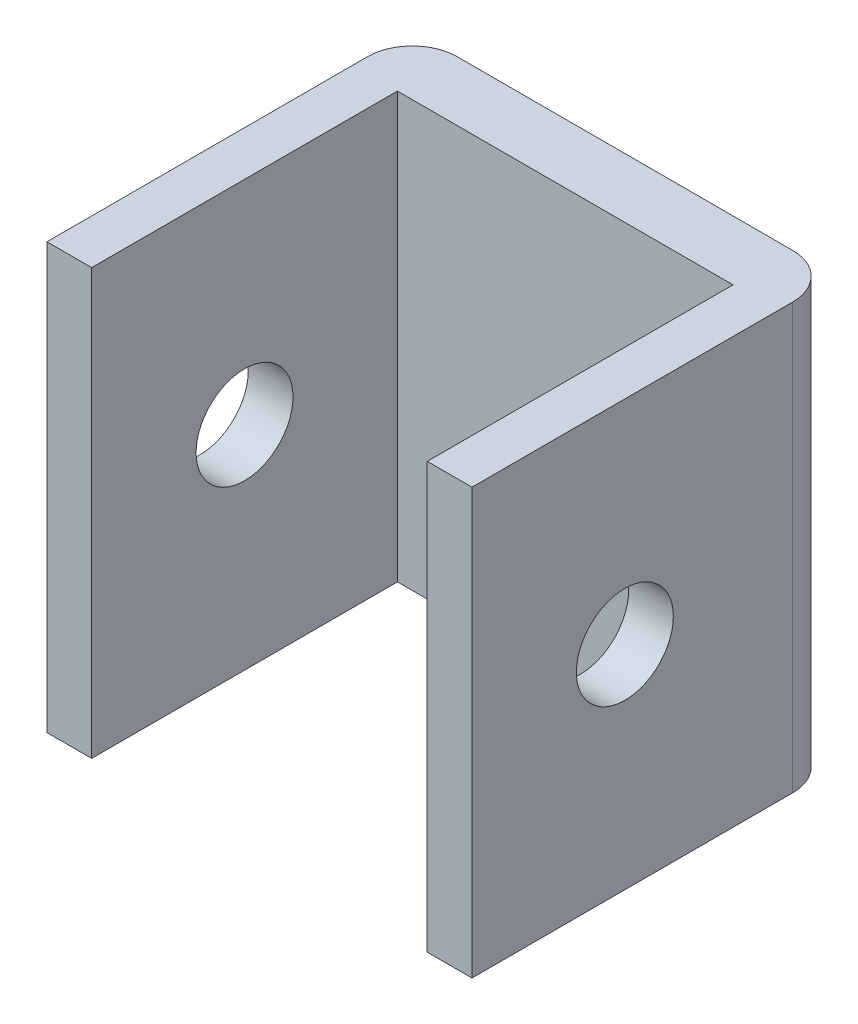
from build123d import *

# Parameters (mm, degrees)
BOSS_EXTRUDE1_DEPTH      = 14.25
BOSS_EXTRUDE1_DEPTH_BACK = 14.25
SKETCH2_R                = 5
BOSS_EXTRUDE2_DEPTH      = 7
SKETCH3_R                = 2.25
CUT_EXTRUDE1_DEPTH       = 1.5
SKETCH4_R                = 1.5
CUT_EXTRUDE2_DEPTH       = 10.5
SKETCH5_R                = 3.25
CUT_EXTRUDE3_DEPTH       = 32.5


with BuildPart() as part:
    # Sketch1 → Boss-Extrude1 (new, two sides: drawn at the far end of the back side and taken through both)
    with BuildSketch(Plane(origin=(0, 0, 0), x_dir=(1, 0, 0), z_dir=(0, 1, 0)).offset(-BOSS_EXTRUDE1_DEPTH_BACK)):
        with BuildLine():
            Line((-14.25, 9.25), (-14.25, -12.25))
            Line((-14.25, -12.25), (-11.25, -12.25))
            Line((-11.25, -12.25), (-11.25, 8.25))
            Line((-11.25, 8.25), (11.25, 8.25))
            Line((11.25, 8.25), (11.25, -12.25))
            Line((11.25, -12.25), (14.25, -12.25))
            Line((14.25, -12.25), (14.25, 9.25))
            ThreePointArc((14.25, 9.25), (13.371320344, 11.371320344), (11.25, 12.25))
            Line((11.25, 12.25), (-11.25, 12.25))
            ThreePointArc((-11.25, 12.25), (-13.371320344, 11.371320344), (-14.25, 9.25))
        make_face()
    extrude(amount=BOSS_EXTRUDE1_DEPTH + BOSS_EXTRUDE1_DEPTH_BACK)

    # Sketch2 → Boss-Extrude2 (add)
    with BuildSketch(Plane(origin=(0, 0, -12.25), x_dir=(-1, 0, 0), z_dir=(0, 0, -1))):
        Circle(SKETCH2_R)
    extrude(amount=BOSS_EXTRUDE2_DEPTH)

    # Sketch3 → Cut-Extrude1 (cut)
    with BuildSketch(Plane(origin=(0, 0, -19.25), x_dir=(-1, 0, 0), z_dir=(0, 0, -1))):
        Circle(SKETCH3_R)
    extrude(amount=-CUT_EXTRUDE1_DEPTH, mode=Mode.SUBTRACT)

    # Sketch4 → Cut-Extrude2 (cut)
    with BuildSketch(Plane(origin=(0, 0, -17.75), x_dir=(-1, 0, 0), z_dir=(0, 0, -1))):
        Circle(SKETCH4_R)
    extrude(amount=-CUT_EXTRUDE2_DEPTH, mode=Mode.SUBTRACT)

    # Sketch5 → Cut-Extrude3 (cut)
    with BuildSketch(Plane(origin=(14.25, 0, 0), x_dir=(0, 0, -1), z_dir=(1, 0, 0))):
        with Locations((-2, 0)):
            Circle(SKETCH5_R)
    extrude(amount=-CUT_EXTRUDE3_DEPTH, mode=Mode.SUBTRACT)


solid = part.part
